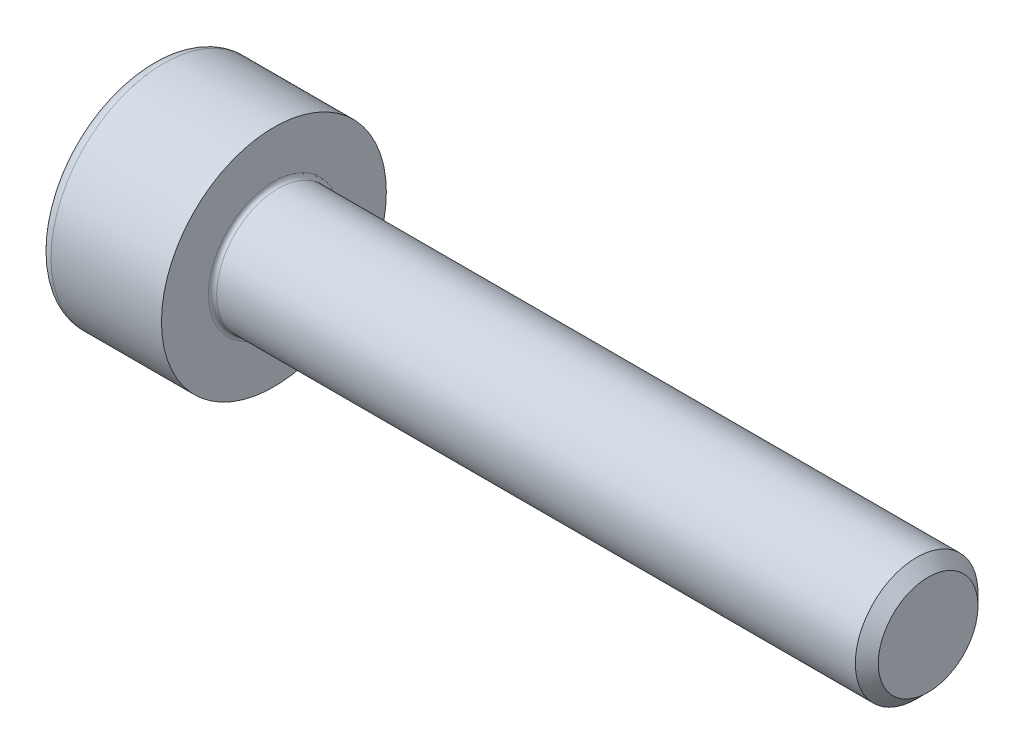
from build123d import *

# Parameters (mm, degrees)
FILLET1_R   = 0.1
FILLET2_R   = 0.3
HEX_2_DEPTH = 1.3


with BuildPart() as part:
    # BodySke → Base-Revolve (revolve)
    with BuildSketch(Plane.XY):
        Polygon((0, 0), (0, 2.75), (3, 2.75), (3, 1.5), (18.7195, 1.5), (19, 1.2195), (19, 0), align=None)
    revolve(axis=Axis((-31.75, 0, 0), (1, 0, 0)))

    # Fillet1
    fillet1_edges = [part.edges().sort_by_distance(p)[0] for p in [
        (3, -1.5, 0),
    ]]
    fillet(fillet1_edges, radius=FILLET1_R)

    # Fillet2
    fillet2_edges = [part.edges().sort_by_distance(p)[0] for p in [
        (0, -2.75, 0),
    ]]
    fillet(fillet2_edges, radius=FILLET2_R)

    # Sketch2 → Hex-PreBroach (revolve, cut)
    with BuildSketch(Plane.XY):
        Polygon((0, 1.26), (1.3, 1.26), (2.027461339, 0), (0, 0), align=None)
    revolve(axis=Axis((0, 0, 0), (1, 0, 0)), mode=Mode.SUBTRACT)

    # Sketch3 → Hex 2 (cut)
    with BuildSketch(Plane(origin=(0, 0, 0), x_dir=(0, 0.5, 0.866025404), z_dir=(-1, 0, 0))):
        Polygon((0.727461339, 1.26), (-0.727461339, 1.26), (-1.454922678, 0), (-0.727461339, -1.26), (0.727461339, -1.26), (1.454922678, 0), align=None)
    extrude(amount=-HEX_2_DEPTH, mode=Mode.SUBTRACT)


solid = part.part
